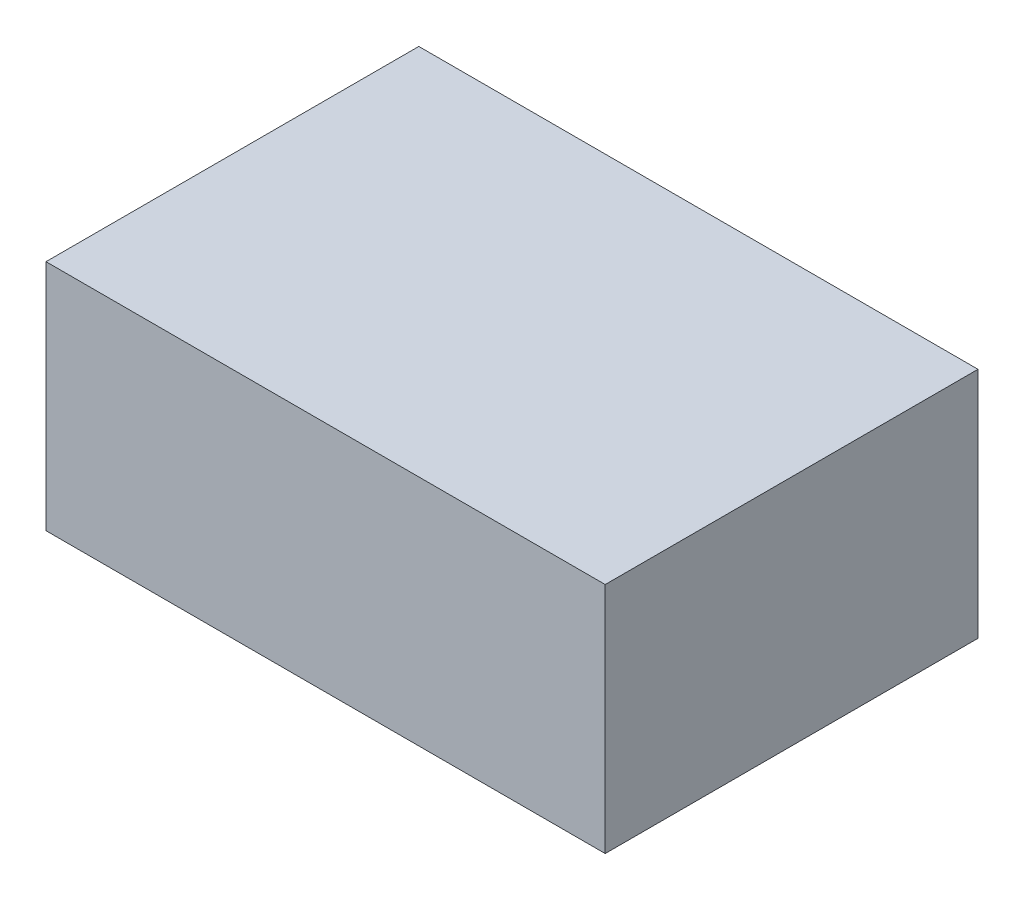
from build123d import *

# Parameters (mm, degrees)
SKETCH1_W           = 304.8
SKETCH1_H           = 203.2
BOSS_EXTRUDE1_DEPTH = 63.5


with BuildPart() as part:
    # Sketch1 → Boss-Extrude1 (new body, symmetric)
    with BuildSketch(Plane(origin=(0, 0, 0), x_dir=(1, 0, 0), z_dir=(0, 1, 0))):
        Rectangle(SKETCH1_W, SKETCH1_H)
    extrude(amount=BOSS_EXTRUDE1_DEPTH, both=True)


solid = part.part
